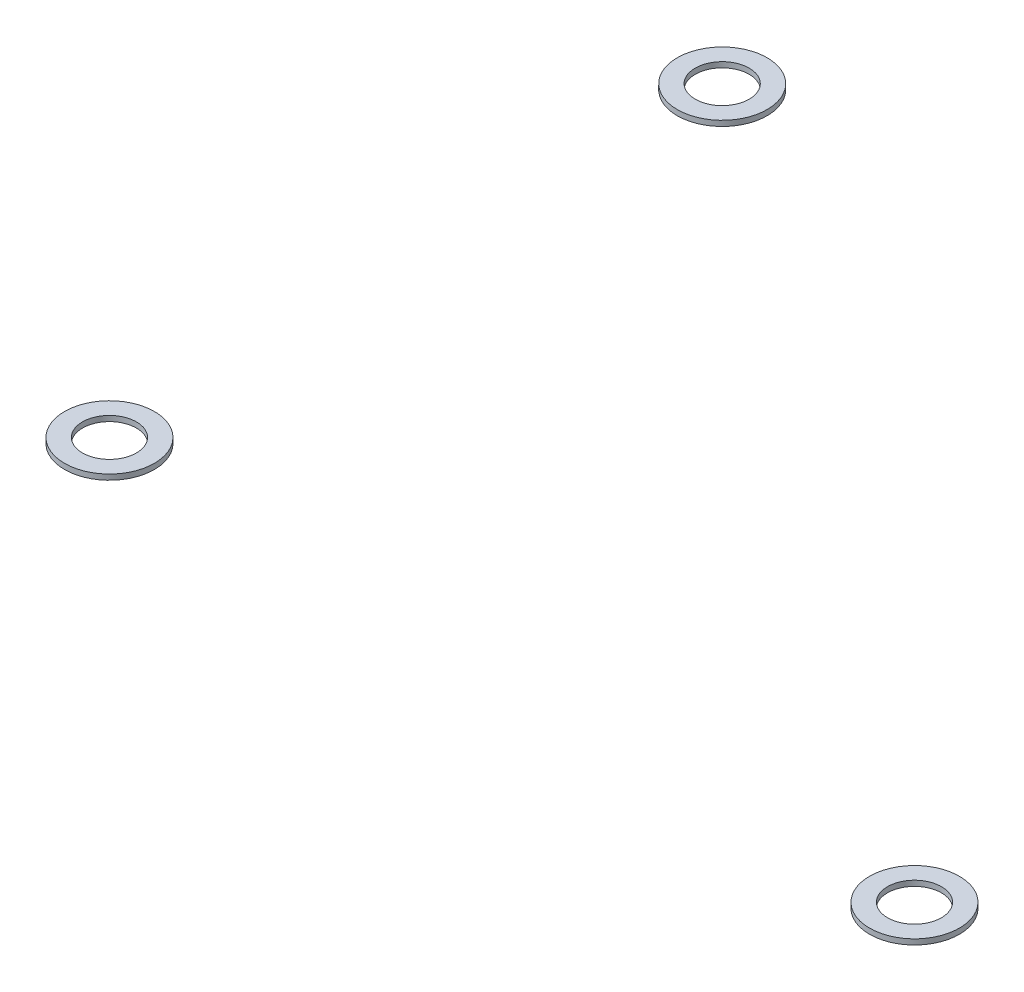
from build123d import *

# Parameters (mm, degrees)
SKETCH1_R             = 2.5
SKETCH1_R_2           = 1.5
BOSS_EXTRUDE1_DEPTH   = 0.3
BOSS_EXTRUDE1_2_DEPTH = 0.3
BOSS_EXTRUDE1_3_DEPTH = 0.3


with BuildPart() as part:
    # Sketch1 → Boss-Extrude1 (new body)
    with BuildSketch(Plane(origin=(0, 0, 0), x_dir=(1, 0, 0), z_dir=(0, 1, 0))):
        with Locations((-22.4, 17.05)):
            Circle(SKETCH1_R)
        with Locations((-22.4, 17.05)):
            Circle(SKETCH1_R_2, mode=Mode.SUBTRACT)
    extrude(amount=BOSS_EXTRUDE1_DEPTH)


with BuildPart() as body_2:
    # Sketch1 → Boss-Extrude1 2 (new body)
    with BuildSketch(Plane(origin=(0, 0, 0), x_dir=(1, 0, 0), z_dir=(0, 1, 0))):
        with Locations((-22.4, -17.05)):
            Circle(SKETCH1_R)
        with Locations((-22.4, -17.05)):
            Circle(SKETCH1_R_2, mode=Mode.SUBTRACT)
    extrude(amount=BOSS_EXTRUDE1_2_DEPTH)


with BuildPart() as body_3:
    # Sketch1 → Boss-Extrude1 3 (new body)
    with BuildSketch(Plane(origin=(0, 0, 0), x_dir=(1, 0, 0), z_dir=(0, 1, 0))):
        with Locations((22.4, -17.05)):
            Circle(SKETCH1_R)
        with Locations((22.4, -17.05)):
            Circle(SKETCH1_R_2, mode=Mode.SUBTRACT)
    extrude(amount=BOSS_EXTRUDE1_3_DEPTH)


solid = Compound([part.part, body_2.part, body_3.part])
